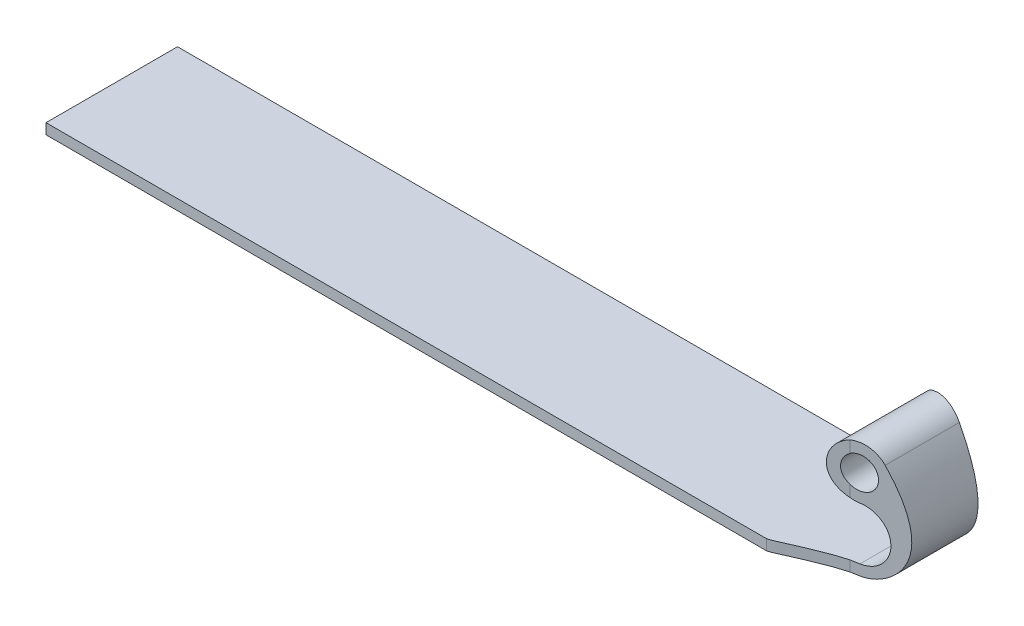
from build123d import *

# Parameters (mm, degrees)
SKETCH1_W               = 76.2
SKETCH1_H               = 12.7
BOSS_EXTRUDE1_DEPTH     = 1.016
SKETCH2_R               = 1.524
BOSS_EXTRUDE2_DEPTH     = 12.7
CUT_EXTRUDE1_DEPTH      = 10
CUT_EXTRUDE1_DEPTH_BACK = 11.1600001


with BuildPart() as part:
    # Sketch1 → Boss-Extrude1 (new body)
    with BuildSketch(Plane(origin=(0, 0, 0), x_dir=(1, 0, 0), z_dir=(0, 1, 0))):
        Rectangle(SKETCH1_W, SKETCH1_H)
    extrude(amount=BOSS_EXTRUDE1_DEPTH)

    # Sketch2 → Boss-Extrude2 (add, through all)
    with BuildSketch(Plane(origin=(0, 0, -6.35), x_dir=(-1, 0, 0), z_dir=(0, 0, -1))):
        with BuildLine():
            Line((38.1, 1.016), (38.1, 0))
            Line((38.1, 0), (-38.1, 0))
            add(Edge.make_bspline(
                [(-38.1, 0), (-40.015605578, 0), (-42.822592097, 1.815276702), (-43.811105253, 4.997519765), (-40.168646494, 10.109873022)],
                knots=[0, 0, 0, 0, 0, 1, 1, 1, 1, 1], degree=4))
            ThreePointArc((-40.168646494, 10.109873022), (-35.842209324, 9.799607005), (-38.1, 6.096))
            ThreePointArc((-38.1, 6.096), (-40.64, 3.556), (-38.1, 1.016))
            Line((-38.1, 1.016), (38.1, 1.016))
        make_face()
        with Locations((-38.1, 8.636)):
            Circle(SKETCH2_R, mode=Mode.SUBTRACT)
    extrude(amount=-BOSS_EXTRUDE2_DEPTH)

    # Sketch3 → Cut-Extrude1 (cut, two sides)
    with BuildSketch(Plane.XZ.offset(-1.016)) as cut_extrude1_sk:
        with BuildLine():
            Line((38.1, -6.35), (38.1, -3.947075763))
            Line((38.1, -3.947075763), (37.273899924, -4.092739495))
            add(Edge.make_bspline(
                [(37.273899924, -4.092739495), (34.703704114, -4.800647246), (31.882848561, -6.35), (31.461872823, -6.35)],
                knots=[0.208615082, 0.208615082, 0.208615082, 0.208615082, 1, 1, 1, 1], degree=3))
            Line((31.461872823, -6.35), (38.1, -6.35))
        make_face()
        Polygon((42.354063476, -3.196969595), (39.205663033, -3.752117539), (38.1, -3.947075763), (38.1, -6.35), (42.354063476, -6.35), align=None)
        Polygon((38.1, 3.947075763), (39.205663033, 3.752117539), (42.354063476, 3.196969595), (42.354063476, 6.35), (38.1, 6.35), align=None)
        with BuildLine():
            Line((37.273899924, 4.092739495), (38.1, 3.947075763))
            Line((38.1, 3.947075763), (38.1, 6.35))
            Line((38.1, 6.35), (31.461872823, 6.35))
            add(Edge.make_bspline(
                [(37.273899924, 4.092739495), (34.703704114, 4.800647246), (31.882848561, 6.35), (31.461872823, 6.35)],
                knots=[0.208615082, 0.208615082, 0.208615082, 0.208615082, 1, 1, 1, 1], degree=3))
        make_face()
    extrude(amount=CUT_EXTRUDE1_DEPTH, mode=Mode.SUBTRACT)
    extrude(cut_extrude1_sk.sketch, amount=-CUT_EXTRUDE1_DEPTH_BACK, mode=Mode.SUBTRACT)


solid = part.part
